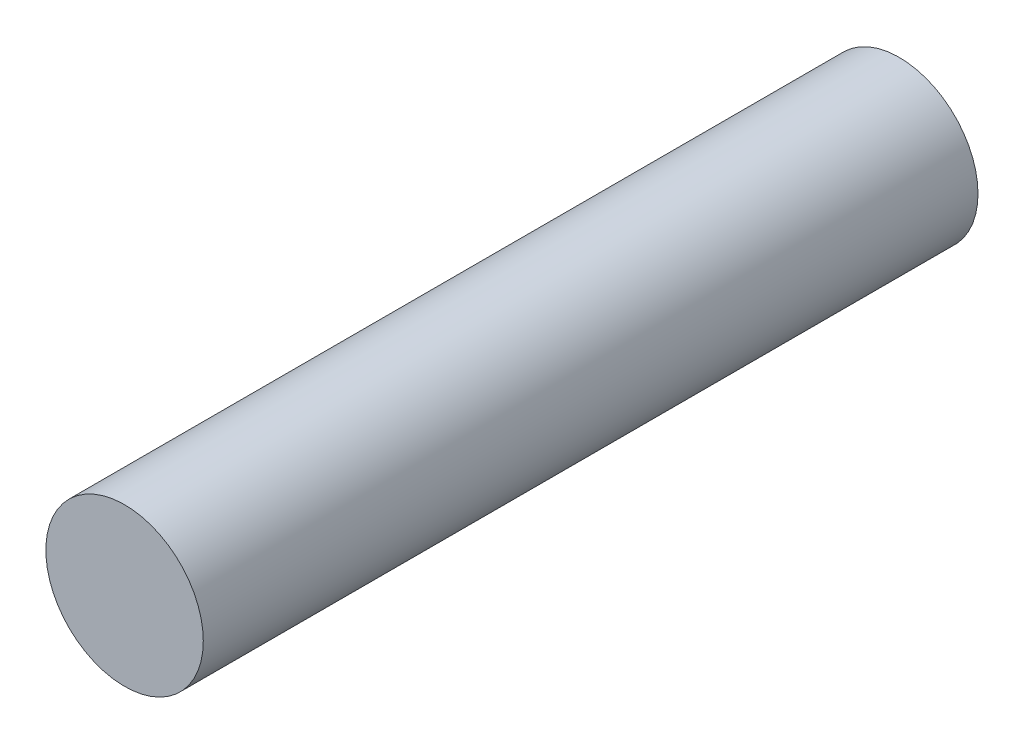
from build123d import *

# Parameters (mm, degrees)
SKETCH1_R           = 8.001
BOSS_EXTRUDE1_DEPTH = 78.74


with BuildPart() as part:
    # Sketch1 → Boss-Extrude1 (new body)
    with BuildSketch(Plane.XY):
        Circle(SKETCH1_R)
    extrude(amount=BOSS_EXTRUDE1_DEPTH)


solid = part.part
